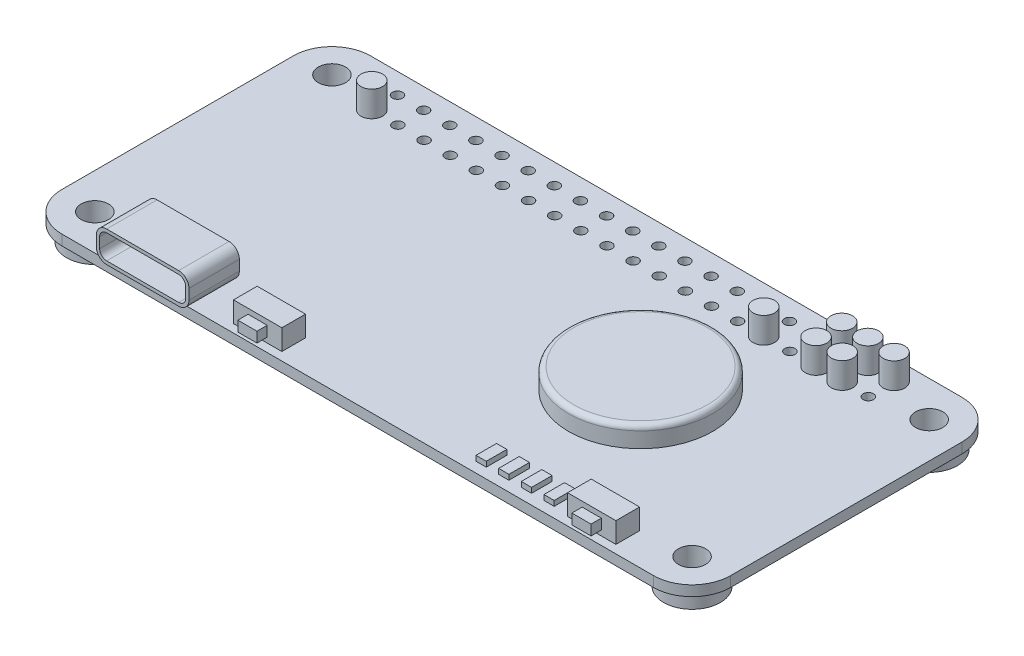
from build123d import *

# Parameters (mm, degrees)
BOSS_EXTRUDE1_DEPTH      = 1
SKETCH2_R                = 1.325
CUT_EXTRUDE1_DEPTH       = 2
SKETCH3_R                = 0.5
CUT_EXTRUDE2_DEPTH       = 2
LPATTERN1_COUNT          = 20
LPATTERN1_PITCH          = 2.54
BOSS_EXTRUDE6_DEPTH      = 0.4
BOSS_EXTRUDE6_DEPTH_BACK = 4.5
CUT_EXTRUDE9_DEPTH       = 5.25
SKETCH_1_W               = 4.7
SKETCH_1_H               = 2.3
EXTRUDE_1_DEPTH          = 2
SKETCH_2_W               = 1.86
SKETCH_2_H               = 1
EXTRUDE_2_DEPTH          = 1
SKETCH_9_R               = 2.75
SKETCH_9_R_2             = 1.325
EXTRUDE_8_DEPTH          = 1.5
SKETCH_10_R              = 1.05
EXTRUDE_9_DEPTH          = 2.5
SKETCH_11_R              = 0.5
EXTRUDE_10_DEPTH         = 3
SKETCH_12_R              = 7
EXTRUDE_11_DEPTH         = 2
SKETCH_13_W              = 1
SKETCH_13_H              = 2
EXTRUDE_12_DEPTH         = 0.5
FILLET_1_R               = 0.5
EXTRUDE_13_DEPTH         = 1


with BuildPart() as part:
    # Sketch1 → Boss-Extrude1 (new body)
    with BuildSketch(Plane(origin=(0, 0, 0), x_dir=(1, 0, 0), z_dir=(0, 1, 0))):
        with BuildLine():
            Line((-28.75, 15), (28.75, 15))
            ThreePointArc((28.75, 15), (31.401650429, 13.901650429), (32.5, 11.25))
            Line((32.5, 11.25), (32.5, -11.25))
            ThreePointArc((32.5, -11.25), (31.401650429, -13.901650429), (28.75, -15))
            Line((28.75, -15), (-28.75, -15))
            ThreePointArc((-28.75, -15), (-31.401650429, -13.901650429), (-32.5, -11.25))
            Line((-32.5, -11.25), (-32.5, 11.25))
            ThreePointArc((-32.5, 11.25), (-31.401650429, 13.901650429), (-28.75, 15))
        make_face()
    extrude(amount=BOSS_EXTRUDE1_DEPTH)

    # Sketch2 → Cut-Extrude1 (cut, through all)
    with BuildSketch(Plane(origin=(0, 1, 0), x_dir=(1, 0, 0), z_dir=(0, 1, 0))):
        with Locations((-29.025, 11.525)):
            Circle(SKETCH2_R)
        with Locations((29.025, 11.525)):
            Circle(SKETCH2_R)
        with Locations((29.025, -11.525)):
            Circle(SKETCH2_R)
        with Locations((-29.025, -11.525)):
            Circle(SKETCH2_R)
    extrude(amount=-CUT_EXTRUDE1_DEPTH, mode=Mode.SUBTRACT)

    # Sketch3 → Cut-Extrude2 (cut, through all)
    with BuildSketch(Plane(origin=(0, 1, 0), x_dir=(1, 0, 0), z_dir=(0, 1, 0))):
        with Locations((-24.128, 13)):
            Circle(SKETCH3_R)
        with Locations((-24.128, 10.5)):
            Circle(SKETCH3_R)
    cut_extrude2 = extrude(amount=-CUT_EXTRUDE2_DEPTH, mode=Mode.SUBTRACT)

    # LPattern1: Cut-Extrude2 ×20
    with Locations(*[(i * LPATTERN1_PITCH, 0, 0) for i in range(1, LPATTERN1_COUNT)]):
        add(cut_extrude2, mode=Mode.SUBTRACT)

    # Sketch15 → Boss-Extrude6 (add, two sides)
    with BuildSketch(Plane.XY.offset(15)) as boss_extrude6_sk:
        with BuildLine():
            Line((-24, 4), (-17, 4))
            ThreePointArc((-17, 4), (-16.292893219, 3.707106781), (-16, 3))
            Line((-16, 3), (-16, 2))
            ThreePointArc((-16, 2), (-16.292893219, 1.292893219), (-17, 1))
            Line((-17, 1), (-24, 1))
            ThreePointArc((-24, 1), (-24.707106781, 1.292893219), (-25, 2))
            Line((-25, 2), (-25, 3))
            ThreePointArc((-25, 3), (-24.707106781, 3.707106781), (-24, 4))
        make_face()
    extrude(amount=BOSS_EXTRUDE6_DEPTH)
    extrude(boss_extrude6_sk.sketch, amount=-BOSS_EXTRUDE6_DEPTH_BACK)

    # Sketch16 → Cut-Extrude9 (cut)
    with BuildSketch(Plane.XY.offset(15.4)):
        with BuildLine():
            Line((-17, 3.68), (-24, 3.68))
            ThreePointArc((-24, 3.68), (-24.480832611, 3.480832611), (-24.68, 3))
            Line((-24.68, 3), (-24.68, 2))
            ThreePointArc((-24.68, 2), (-24.480832611, 1.519167389), (-24, 1.32))
            Line((-24, 1.32), (-17, 1.32))
            ThreePointArc((-17, 1.32), (-16.519167389, 1.519167389), (-16.32, 2))
            Line((-16.32, 2), (-16.32, 3))
            ThreePointArc((-16.32, 3), (-16.519167389, 3.480832611), (-17, 3.68))
        make_face()
    extrude(amount=-CUT_EXTRUDE9_DEPTH, mode=Mode.SUBTRACT)

    # 草图1 → 凸台-拉伸1 (add)
    with BuildSketch(Plane(origin=(0, 1, 0), x_dir=(1, 0, 0), z_dir=(0, 1, 0))):
        with Locations((-10.52, -13.05)):
            Rectangle(SKETCH_1_W, SKETCH_1_H)
        with Locations((21.95, -13.05)):
            Rectangle(SKETCH_1_W, SKETCH_1_H)
    extrude(amount=EXTRUDE_1_DEPTH)

    # 草图2 → 凸台-拉伸2 (add)
    with BuildSketch(Plane.XY.offset(14.2)):
        with Locations((-10.52, 2)):
            Rectangle(SKETCH_2_W, SKETCH_2_H)
        with Locations((21.95, 2)):
            Rectangle(SKETCH_2_W, SKETCH_2_H)
    extrude(amount=EXTRUDE_2_DEPTH)

    # 草图9 → 凸台-拉伸8 (add)
    with BuildSketch(Plane.XZ):
        with Locations((29.025, 11.525)):
            Circle(SKETCH_9_R)
        with Locations((29.025, 11.525)):
            Circle(SKETCH_9_R_2, mode=Mode.SUBTRACT)
        with Locations((29.025, -11.525)):
            Circle(SKETCH_9_R)
        with Locations((29.025, -11.525)):
            Circle(SKETCH_9_R_2, mode=Mode.SUBTRACT)
        with Locations((-29.025, 11.525)):
            Circle(SKETCH_9_R)
        with Locations((-29.025, 11.525)):
            Circle(SKETCH_9_R_2, mode=Mode.SUBTRACT)
        with Locations((-29.025, -11.525)):
            Circle(SKETCH_9_R)
        with Locations((-29.025, -11.525)):
            Circle(SKETCH_9_R_2, mode=Mode.SUBTRACT)
    extrude(amount=EXTRUDE_8_DEPTH)

    # 草图10 → 凸台-拉伸9 (add)
    with BuildSketch(Plane(origin=(0, 1, 0), x_dir=(1, 0, 0), z_dir=(0, 1, 0))):
        with Locations((24.132, 13)):
            Circle(SKETCH_10_R)
        with Locations((21.592, 13)):
            Circle(SKETCH_10_R)
        with Locations((19.052, 13)):
            Circle(SKETCH_10_R)
        with Locations((21.592, 10.5)):
            Circle(SKETCH_10_R)
        with Locations((19.052, 10.5)):
            Circle(SKETCH_10_R)
        with Locations((-24.128, 10.5)):
            Circle(SKETCH_10_R)
        with Locations((13.972, 10.5)):
            Circle(SKETCH_10_R)
    extrude(amount=EXTRUDE_9_DEPTH)

    # 草图11 → 凸台-拉伸10 (add)
    with BuildSketch(Plane.XZ.offset(-1)):
        with Locations((24.132, -13)):
            Circle(SKETCH_11_R)
        with Locations((21.592, -13)):
            Circle(SKETCH_11_R)
        with Locations((21.592, -10.5)):
            Circle(SKETCH_11_R)
        with Locations((19.052, -10.5)):
            Circle(SKETCH_11_R)
        with Locations((19.052, -13)):
            Circle(SKETCH_11_R)
        with Locations((-24.128, -10.5)):
            Circle(SKETCH_11_R)
    extrude(amount=EXTRUDE_10_DEPTH)

    # 草图12 → 凸台-拉伸11 (add)
    with BuildSketch(Plane(origin=(0, 1, 0), x_dir=(1, 0, 0), z_dir=(0, 1, 0))):
        with Locations((12.5, 0)):
            Circle(SKETCH_12_R)
    extrude(amount=EXTRUDE_11_DEPTH)

    # 草图13 → 凸台-拉伸12 (add)
    with BuildSketch(Plane(origin=(0, 1, 0), x_dir=(1, 0, 0), z_dir=(0, 1, 0))):
        with Locations((17.6, -13)):
            Rectangle(SKETCH_13_W, SKETCH_13_H)
        with Locations((15.4, -13)):
            Rectangle(SKETCH_13_W, SKETCH_13_H)
        with Locations((13.2, -13)):
            Rectangle(SKETCH_13_W, SKETCH_13_H)
        with Locations((11, -13)):
            Rectangle(SKETCH_13_W, SKETCH_13_H)
    extrude(amount=EXTRUDE_12_DEPTH)

    # 圆角1
    fillet_1_edges = [part.edges().sort_by_distance(p)[0] for p in [
        (5.5, 3, 0),
    ]]
    fillet(fillet_1_edges, radius=FILLET_1_R)

    # 草图14 → 凸台-拉伸13 (add)
    with BuildSketch(Plane(origin=(0, 0, 10.5), x_dir=(-1, 0, 0), z_dir=(0, 0, -1))):
        with BuildLine():
            Line((16, 3), (16, 2))
            ThreePointArc((16, 2), (16.292893219, 1.292893219), (17, 1))
            Line((17, 1), (24, 1))
            ThreePointArc((24, 1), (24.707106781, 1.292893219), (25, 2))
            Line((25, 2), (25, 3))
            ThreePointArc((25, 3), (24.707106781, 3.707106781), (24, 4))
            Line((24, 4), (17, 4))
            ThreePointArc((17, 4), (16.292893219, 3.707106781), (16, 3))
        make_face()
    extrude(amount=-EXTRUDE_13_DEPTH)


solid = part.part
